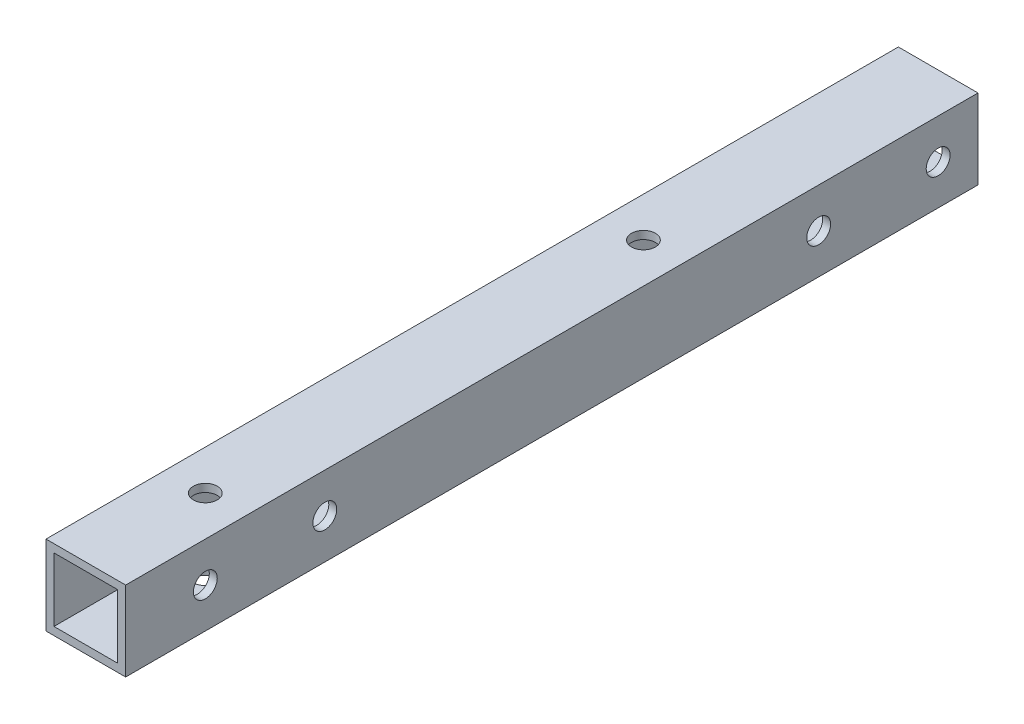
from build123d import *

# Parameters (mm, degrees)
SKETCH_1_W          = 10
SKETCH_1_H          = 10
SKETCH_1_W_2        = 8
SKETCH_1_H_2        = 8
EXTRUDE_1_DEPTH     = 107
SKETCH_2_R          = 1.5
CUT_EXTRUDE_1_DEPTH = 11
SKETCH_3_R          = 1.5
CUT_EXTRUDE_2_DEPTH = 10


with BuildPart() as part:
    # 草图1 → 拉伸-薄壁1 (new body)
    with BuildSketch(Plane.XY):
        Rectangle(SKETCH_1_W, SKETCH_1_H)
        Rectangle(SKETCH_1_W_2, SKETCH_1_H_2, mode=Mode.SUBTRACT)
    extrude(amount=EXTRUDE_1_DEPTH)

    # 草图2 → 切除-拉伸1 (cut, through all)
    with BuildSketch(Plane(origin=(5, 0, 0), x_dir=(0, 0, -1), z_dir=(1, 0, 0))):
        with Locations((-5, 0)):
            Circle(SKETCH_2_R)
        with Locations((-20, 0)):
            Circle(SKETCH_2_R)
        with Locations((-97, 0)):
            Circle(SKETCH_2_R)
        with Locations((-82, 0)):
            Circle(SKETCH_2_R)
    extrude(amount=-CUT_EXTRUDE_1_DEPTH, mode=Mode.SUBTRACT)

    # 草图3 → 切除-拉伸2 (cut)
    with BuildSketch(Plane.XZ.offset(5)):
        with Locations((0, 92)):
            Circle(SKETCH_3_R)
        with Locations((0, 37)):
            Circle(SKETCH_3_R)
    extrude(amount=-CUT_EXTRUDE_2_DEPTH, mode=Mode.SUBTRACT)


solid = part.part
